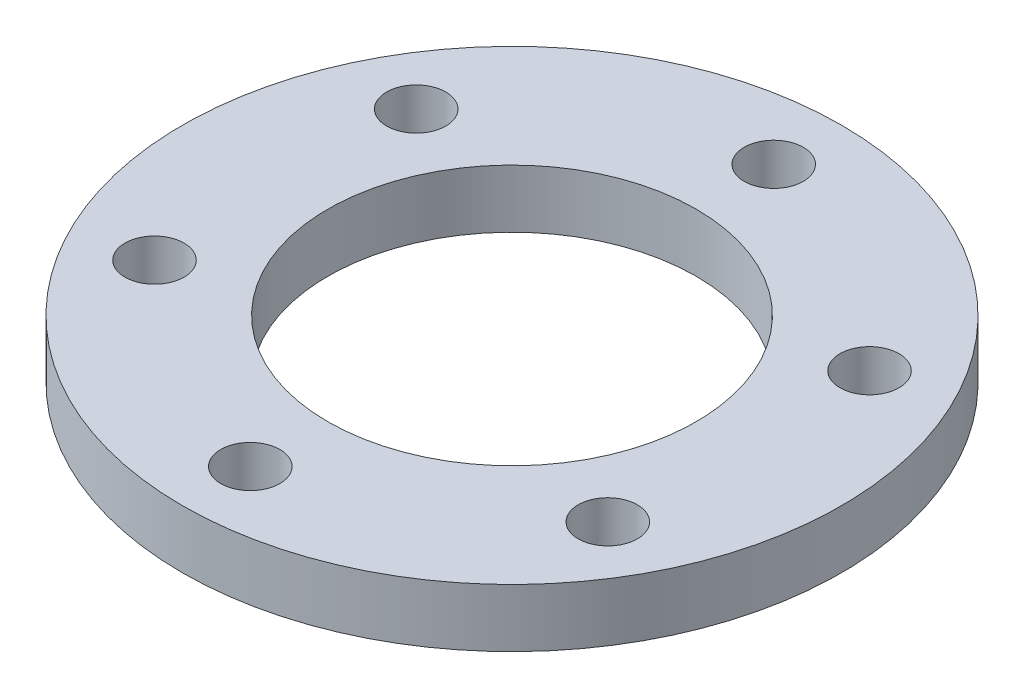
from build123d import *

# Parameters (mm, degrees)
SKETCH_1_R          = 17
SKETCH_1_R_2        = 9.5
EXTRUDE_1_DEPTH     = 3
SKETCH_2_R          = 1.525
CUT_EXTRUDE_1_DEPTH = 100


with BuildPart() as part:
    # 草图1 → 凸台-拉伸1 (new body)
    with BuildSketch(Plane(origin=(0, 0, 0), x_dir=(1, 0, 0), z_dir=(0, 1, 0))):
        Circle(SKETCH_1_R)
        Circle(SKETCH_1_R_2, mode=Mode.SUBTRACT)
    extrude(amount=EXTRUDE_1_DEPTH)

    # 草图2 → 切除-拉伸1 (cut)
    with BuildSketch(Plane(origin=(0, 3, 0), x_dir=(1, 0, 0), z_dir=(0, 1, 0))):
        with Locations((0, 13.5)):
            Circle(SKETCH_2_R)
        with Locations((11.691342951, 6.75)):
            Circle(SKETCH_2_R)
        with Locations((11.691342951, -6.75)):
            Circle(SKETCH_2_R)
        with Locations((0, -13.5)):
            Circle(SKETCH_2_R)
        with Locations((-11.691342951, -6.75)):
            Circle(SKETCH_2_R)
        with Locations((-11.691342951, 6.75)):
            Circle(SKETCH_2_R)
    extrude(amount=-CUT_EXTRUDE_1_DEPTH, mode=Mode.SUBTRACT)


solid = part.part
